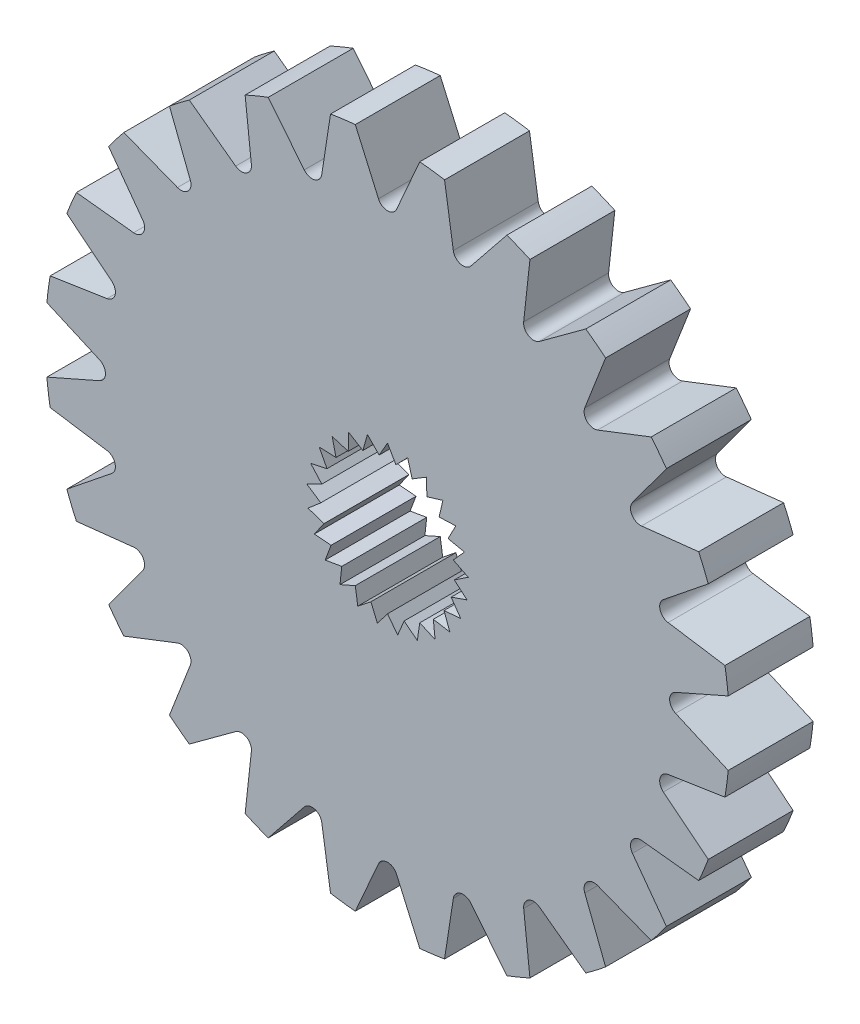
from build123d import *

# Parameters (mm, degrees)
SKETCH1_R           = 12.893401015
BOSS_EXTRUDE1_DEPTH = 3.2004
CUT_EXTRUDE1_DEPTH  = 3.2004


with BuildPart() as part:
    # Sketch1 → Boss-Extrude1 (new body)
    with BuildSketch(Plane.XY):
        Circle(SKETCH1_R)
        Polygon((0, 3.048), (-0.315924789, 2.500802214), (-0.758006776, 2.952241475), (-0.927923651, 2.343667613), (-1.468385199, 2.670982761), (-1.481617658, 2.039271757), (-2.086499579, 2.221896376), (-1.942216178, 1.606740957), (-2.573511517, 1.633200071), (-2.280778112, 1.073252713), (-2.898820262, 0.941883799), (-2.47603037, 0.472328054), (-3.041985468, 0.191385504), (-2.515704533, -0.158274714), (-2.99401154, -0.571138247), (-2.397307729, -0.778932499), (-2.757912856, -1.297775281), (-2.128279263, -1.350647091), (-2.348524364, -1.942868321), (-1.725523184, -1.837495558), (-1.791569449, -2.465883799), (-1.214346137, -2.208887422), (-1.122043637, -2.833958729), (-0.626867256, -2.441486766), (-0.382015696, -3.02396561), (0, -2.520678517), (0.382015696, -3.02396561), (0.626867256, -2.441486766), (1.122043637, -2.833958729), (1.214346137, -2.208887422), (1.791569449, -2.465883799), (1.725523184, -1.837495558), (2.348524364, -1.942868321), (2.128279263, -1.350647091), (2.757912856, -1.297775281), (2.397307729, -0.778932499), (2.99401154, -0.571138247), (2.515704533, -0.158274714), (3.041985468, 0.191385504), (2.47603037, 0.472328054), (2.898820262, 0.941883799), (2.280778112, 1.073252713), (2.573511517, 1.633200071), (1.942216178, 1.606740957), (2.086499579, 2.221896376), (1.481617658, 2.039271757), (1.468385199, 2.670982761), (0.927923651, 2.343667613), (0.758006776, 2.952241475), (0.315924789, 2.500802214), align=None, mode=Mode.SUBTRACT)
    extrude(amount=BOSS_EXTRUDE1_DEPTH)

    # Sketch2 → Cut-Extrude1 (cut)
    with BuildSketch(Plane.XY.offset(3.2004)):
        with BuildLine():
            Line((-1.215131366, 12.836013614), (-0.341888634, 10.852413458))
            ThreePointArc((-0.341888634, 10.852413458), (0, 10.629371487), (0.341888634, 10.852413458))
            Line((0.341888634, 10.852413458), (1.215131366, 12.836013614))
            ThreePointArc((1.215131366, 12.836013614), (0, 12.893401015), (-1.215131366, 12.836013614))
        make_face()
        with BuildLine():
            Line((3.13905035, 10.394139147), (4.495931555, 12.084137917))
            ThreePointArc((4.495931555, 12.084137917), (3.337057739, 12.454069029), (2.148478018, 12.713136196))
            Line((2.148478018, 12.713136196), (2.478572226, 10.571113727))
            ThreePointArc((2.478572226, 10.571113727), (2.751083778, 10.267184437), (3.13905035, 10.394139147))
        make_face()
        with BuildLine():
            Line((5.722290972, 9.22752143), (7.470341439, 10.50874819))
            ThreePointArc((7.470341439, 10.50874819), (6.446700508, 11.16601282), (5.365672176, 11.723879556))
            Line((5.365672176, 11.723879556), (5.130122486, 9.569410064))
            ThreePointArc((5.130122486, 9.569410064), (5.314685744, 9.205305734), (5.722290972, 9.22752143))
        make_face()
        with BuildLine():
            Line((7.91556692, 7.432063377), (9.935659899, 8.217204641))
            ThreePointArc((9.935659899, 8.217204641), (9.11701129, 9.11701129), (8.217204641, 9.935659899))
            Line((8.217204641, 9.935659899), (7.432063377, 7.91556692))
            ThreePointArc((7.432063377, 7.91556692), (7.516100658, 7.516100658), (7.91556692, 7.432063377))
        make_face()
        with BuildLine():
            Line((9.569410064, 5.130122486), (11.723879556, 5.365672176))
            ThreePointArc((11.723879556, 5.365672176), (11.16601282, 6.446700508), (10.50874819, 7.470341439))
            Line((10.50874819, 7.470341439), (9.22752143, 5.722290972))
            ThreePointArc((9.22752143, 5.722290972), (9.205305734, 5.314685744), (9.569410064, 5.130122486))
        make_face()
        with BuildLine():
            Line((10.571113727, 2.478572226), (12.713136196, 2.148478018))
            ThreePointArc((12.713136196, 2.148478018), (12.454069029, 3.337057739), (12.084137917, 4.495931555))
            Line((12.084137917, 4.495931555), (10.394139147, 3.13905035))
            ThreePointArc((10.394139147, 3.13905035), (10.267184437, 2.751083778), (10.571113727, 2.478572226))
        make_face()
        with BuildLine():
            Line((10.852413458, -0.341888634), (12.836013614, -1.215131366))
            ThreePointArc((12.836013614, -1.215131366), (12.893401015, 0), (12.836013614, 1.215131366))
            Line((12.836013614, 1.215131366), (10.852413458, 0.341888634))
            ThreePointArc((10.852413458, 0.341888634), (10.629371487, 0), (10.852413458, -0.341888634))
        make_face()
        with BuildLine():
            Line((10.394139147, -3.13905035), (12.084137917, -4.495931555))
            ThreePointArc((12.084137917, -4.495931555), (12.454069029, -3.337057739), (12.713136196, -2.148478018))
            Line((12.713136196, -2.148478018), (10.571113727, -2.478572226))
            ThreePointArc((10.571113727, -2.478572226), (10.267184437, -2.751083778), (10.394139147, -3.13905035))
        make_face()
        with BuildLine():
            Line((9.22752143, -5.722290972), (10.50874819, -7.470341439))
            ThreePointArc((10.50874819, -7.470341439), (11.16601282, -6.446700508), (11.723879556, -5.365672176))
            Line((11.723879556, -5.365672176), (9.569410064, -5.130122486))
            ThreePointArc((9.569410064, -5.130122486), (9.205305734, -5.314685744), (9.22752143, -5.722290972))
        make_face()
        with BuildLine():
            Line((7.432063377, -7.91556692), (8.217204641, -9.935659899))
            ThreePointArc((8.217204641, -9.935659899), (9.11701129, -9.11701129), (9.935659899, -8.217204641))
            Line((9.935659899, -8.217204641), (7.91556692, -7.432063377))
            ThreePointArc((7.91556692, -7.432063377), (7.516100658, -7.516100658), (7.432063377, -7.91556692))
        make_face()
        with BuildLine():
            Line((5.130122486, -9.569410064), (5.365672176, -11.723879556))
            ThreePointArc((5.365672176, -11.723879556), (6.446700508, -11.16601282), (7.470341439, -10.50874819))
            Line((7.470341439, -10.50874819), (5.722290972, -9.22752143))
            ThreePointArc((5.722290972, -9.22752143), (5.314685744, -9.205305734), (5.130122486, -9.569410064))
        make_face()
        with BuildLine():
            Line((2.478572226, -10.571113727), (2.148478018, -12.713136196))
            ThreePointArc((2.148478018, -12.713136196), (3.337057739, -12.454069029), (4.495931555, -12.084137917))
            Line((4.495931555, -12.084137917), (3.13905035, -10.394139147))
            ThreePointArc((3.13905035, -10.394139147), (2.751083778, -10.267184437), (2.478572226, -10.571113727))
        make_face()
        with BuildLine():
            Line((-0.341888634, -10.852413458), (-1.215131366, -12.836013614))
            ThreePointArc((-1.215131366, -12.836013614), (0, -12.893401015), (1.215131366, -12.836013614))
            Line((1.215131366, -12.836013614), (0.341888634, -10.852413458))
            ThreePointArc((0.341888634, -10.852413458), (0, -10.629371487), (-0.341888634, -10.852413458))
        make_face()
        with BuildLine():
            Line((-3.13905035, -10.394139147), (-4.495931555, -12.084137917))
            ThreePointArc((-4.495931555, -12.084137917), (-3.337057739, -12.454069029), (-2.148478018, -12.713136196))
            Line((-2.148478018, -12.713136196), (-2.478572226, -10.571113727))
            ThreePointArc((-2.478572226, -10.571113727), (-2.751083778, -10.267184437), (-3.13905035, -10.394139147))
        make_face()
        with BuildLine():
            Line((-5.722290972, -9.22752143), (-7.470341439, -10.50874819))
            ThreePointArc((-7.470341439, -10.50874819), (-6.446700508, -11.16601282), (-5.365672176, -11.723879556))
            Line((-5.365672176, -11.723879556), (-5.130122486, -9.569410064))
            ThreePointArc((-5.130122486, -9.569410064), (-5.314685744, -9.205305734), (-5.722290972, -9.22752143))
        make_face()
        with BuildLine():
            Line((-7.91556692, -7.432063377), (-9.935659899, -8.217204641))
            ThreePointArc((-9.935659899, -8.217204641), (-9.11701129, -9.11701129), (-8.217204641, -9.935659899))
            Line((-8.217204641, -9.935659899), (-7.432063377, -7.91556692))
            ThreePointArc((-7.432063377, -7.91556692), (-7.516100658, -7.516100658), (-7.91556692, -7.432063377))
        make_face()
        with BuildLine():
            Line((-9.569410064, -5.130122486), (-11.723879556, -5.365672176))
            ThreePointArc((-11.723879556, -5.365672176), (-11.16601282, -6.446700508), (-10.50874819, -7.470341439))
            Line((-10.50874819, -7.470341439), (-9.22752143, -5.722290972))
            ThreePointArc((-9.22752143, -5.722290972), (-9.205305734, -5.314685744), (-9.569410064, -5.130122486))
        make_face()
        with BuildLine():
            Line((-10.571113727, -2.478572226), (-12.713136196, -2.148478018))
            ThreePointArc((-12.713136196, -2.148478018), (-12.454069029, -3.337057739), (-12.084137917, -4.495931555))
            Line((-12.084137917, -4.495931555), (-10.394139147, -3.13905035))
            ThreePointArc((-10.394139147, -3.13905035), (-10.267184437, -2.751083778), (-10.571113727, -2.478572226))
        make_face()
        with BuildLine():
            Line((-10.852413458, 0.341888634), (-12.836013614, 1.215131366))
            ThreePointArc((-12.836013614, 1.215131366), (-12.893401015, 0), (-12.836013614, -1.215131366))
            Line((-12.836013614, -1.215131366), (-10.852413458, -0.341888634))
            ThreePointArc((-10.852413458, -0.341888634), (-10.629371487, 0), (-10.852413458, 0.341888634))
        make_face()
        with BuildLine():
            Line((-10.394139147, 3.13905035), (-12.084137917, 4.495931555))
            ThreePointArc((-12.084137917, 4.495931555), (-12.454069029, 3.337057739), (-12.713136196, 2.148478018))
            Line((-12.713136196, 2.148478018), (-10.571113727, 2.478572226))
            ThreePointArc((-10.571113727, 2.478572226), (-10.267184437, 2.751083778), (-10.394139147, 3.13905035))
        make_face()
        with BuildLine():
            Line((-9.22752143, 5.722290972), (-10.50874819, 7.470341439))
            ThreePointArc((-10.50874819, 7.470341439), (-11.16601282, 6.446700508), (-11.723879556, 5.365672176))
            Line((-11.723879556, 5.365672176), (-9.569410064, 5.130122486))
            ThreePointArc((-9.569410064, 5.130122486), (-9.205305734, 5.314685744), (-9.22752143, 5.722290972))
        make_face()
        with BuildLine():
            Line((-7.432063377, 7.91556692), (-8.217204641, 9.935659899))
            ThreePointArc((-8.217204641, 9.935659899), (-9.11701129, 9.11701129), (-9.935659899, 8.217204641))
            Line((-9.935659899, 8.217204641), (-7.91556692, 7.432063377))
            ThreePointArc((-7.91556692, 7.432063377), (-7.516100658, 7.516100658), (-7.432063377, 7.91556692))
        make_face()
        with BuildLine():
            Line((-5.130122486, 9.569410064), (-5.365672176, 11.723879556))
            ThreePointArc((-5.365672176, 11.723879556), (-6.446700508, 11.16601282), (-7.470341439, 10.50874819))
            Line((-7.470341439, 10.50874819), (-5.722290972, 9.22752143))
            ThreePointArc((-5.722290972, 9.22752143), (-5.314685744, 9.205305734), (-5.130122486, 9.569410064))
        make_face()
        with BuildLine():
            Line((-2.478572226, 10.571113727), (-2.148478018, 12.713136196))
            ThreePointArc((-2.148478018, 12.713136196), (-3.337057739, 12.454069029), (-4.495931555, 12.084137917))
            Line((-4.495931555, 12.084137917), (-3.13905035, 10.394139147))
            ThreePointArc((-3.13905035, 10.394139147), (-2.751083778, 10.267184437), (-2.478572226, 10.571113727))
        make_face()
    extrude(amount=-CUT_EXTRUDE1_DEPTH, mode=Mode.SUBTRACT)


solid = part.part
